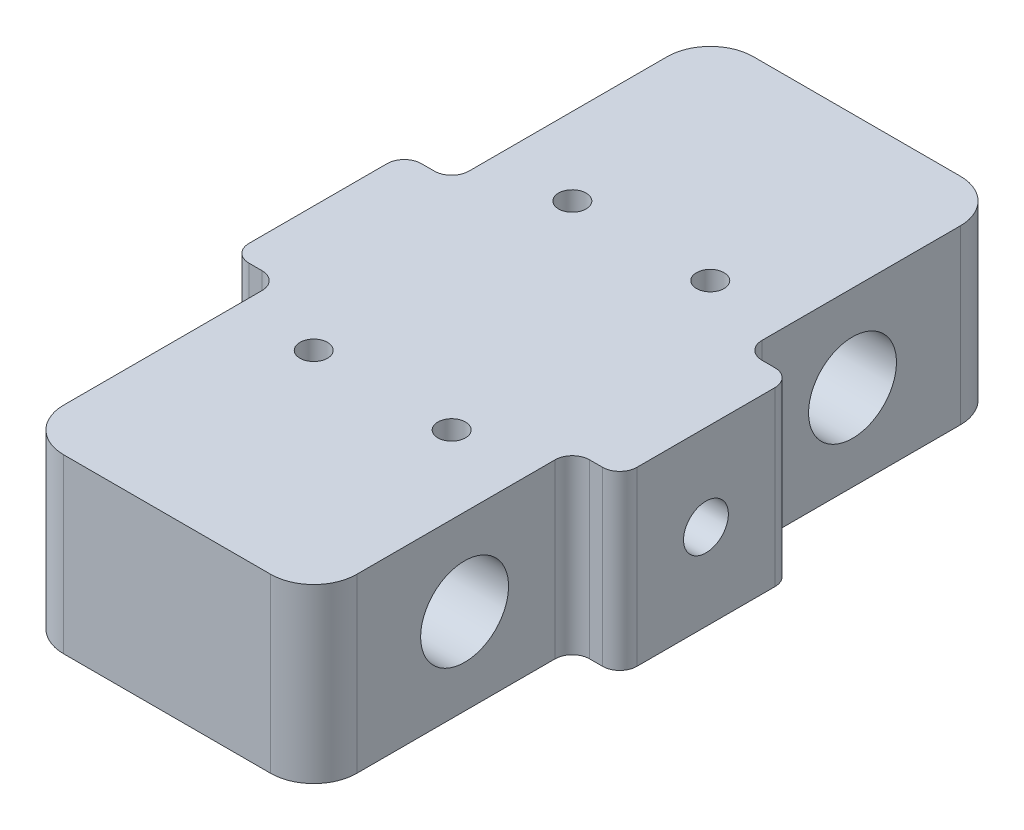
from build123d import *

# Parameters (mm, degrees)
SKETCH_1_W               = 45
SKETCH_1_H               = 80
SKETCH_1_R               = 1.6
EXTRUDE_471_DEPTH        = 20
SKETCH_2_R               = 2.6
CUT_EXTRUDE_665_DEPTH    = 46
SKETCH_3_R               = 5.1
CUT_EXTRUDE_863_DEPTH    = 46
SKETCH_5_W               = 30
SKETCH_5_H               = 20
CUT_EXTRUDE_1108_DEPTH   = 5.5
MIRROR_2_COPY_1_SKETCH_W = 30
MIRROR_2_COPY_1_SKETCH_H = 20
MIRROR_2_COPY_1_DEPTH    = 5.5
FILLET_2_R               = 2
FILLET_5_R               = 5


with BuildPart() as part:
    # 草图1 → Extrude 471 (new body)
    with BuildSketch(Plane(origin=(0, 0, 0), x_dir=(1, 0, 0), z_dir=(0, 1, 0))):
        Rectangle(SKETCH_1_W, SKETCH_1_H)
        with Locations((8, 15)):
            Circle(SKETCH_1_R, mode=Mode.SUBTRACT)
        with Locations((-8, 15)):
            Circle(SKETCH_1_R, mode=Mode.SUBTRACT)
        with Locations((-8, -15)):
            Circle(SKETCH_1_R, mode=Mode.SUBTRACT)
        with Locations((8, -15)):
            Circle(SKETCH_1_R, mode=Mode.SUBTRACT)
    extrude(amount=EXTRUDE_471_DEPTH)

    # 草图2 → Cut-Extrude 665 (cut, through all)
    with BuildSketch(Plane.ZY.offset(22.5)):
        with Locations((0, 10)):
            Circle(SKETCH_2_R)
    extrude(amount=-CUT_EXTRUDE_665_DEPTH, mode=Mode.SUBTRACT)

    # 草图3 → Cut-Extrude 863 (cut, through all)
    with BuildSketch(Plane.ZY.offset(22.5)):
        with Locations((22.5, 10)):
            Circle(SKETCH_3_R)
        with Locations((-22.5, 10)):
            Circle(SKETCH_3_R)
    extrude(amount=-CUT_EXTRUDE_863_DEPTH, mode=Mode.SUBTRACT)

    # 草图5 → Cut-Extrude 1108 (cut)
    with BuildSketch(Plane.ZY.offset(22.5)):
        with Locations((25, 10)):
            Rectangle(SKETCH_5_W, SKETCH_5_H)
    cut_extrude_1108 = extrude(amount=-CUT_EXTRUDE_1108_DEPTH, mode=Mode.SUBTRACT)

    # 镜向1: Cut-Extrude 1108 across plane
    add(cut_extrude_1108.mirror(Plane(origin=(0, 0, 0), x_dir=(0, 0, 1), z_dir=(1, 0, 0))), mode=Mode.SUBTRACT)

    # 镜向2: Cut-Extrude 1108 across plane
    add(cut_extrude_1108.mirror(Plane.XY), mode=Mode.SUBTRACT)

    # 镜向2 copy 1 sketch → 镜向2 copy 1 (cut)
    with BuildSketch(Plane(origin=(22.5, 0, 0), x_dir=(0, 0, -1), z_dir=(1, 0, 0))):
        with Locations((25, 10)):
            Rectangle(MIRROR_2_COPY_1_SKETCH_W, MIRROR_2_COPY_1_SKETCH_H)
    extrude(amount=-MIRROR_2_COPY_1_DEPTH, mode=Mode.SUBTRACT)

    # 圆角2
    fillet_2_edges = [part.edges().sort_by_distance(p)[0] for p in [
        (-22.5, 10, 10),
        (-17, 10, 10),
        (17, 10, 10),
        (22.5, 10, 10),
        (22.5, 10, -10),
        (17, 10, -10),
        (-17, 10, -10),
        (-22.5, 10, -10),
    ]]
    fillet(fillet_2_edges, radius=FILLET_2_R)

    # 圆角5
    fillet_5_edges = [part.edges().sort_by_distance(p)[0] for p in [
        (-17, 10, 40),
        (17, 10, 40),
        (17, 10, -40),
        (-17, 10, -40),
    ]]
    fillet(fillet_5_edges, radius=FILLET_5_R)


solid = part.part
